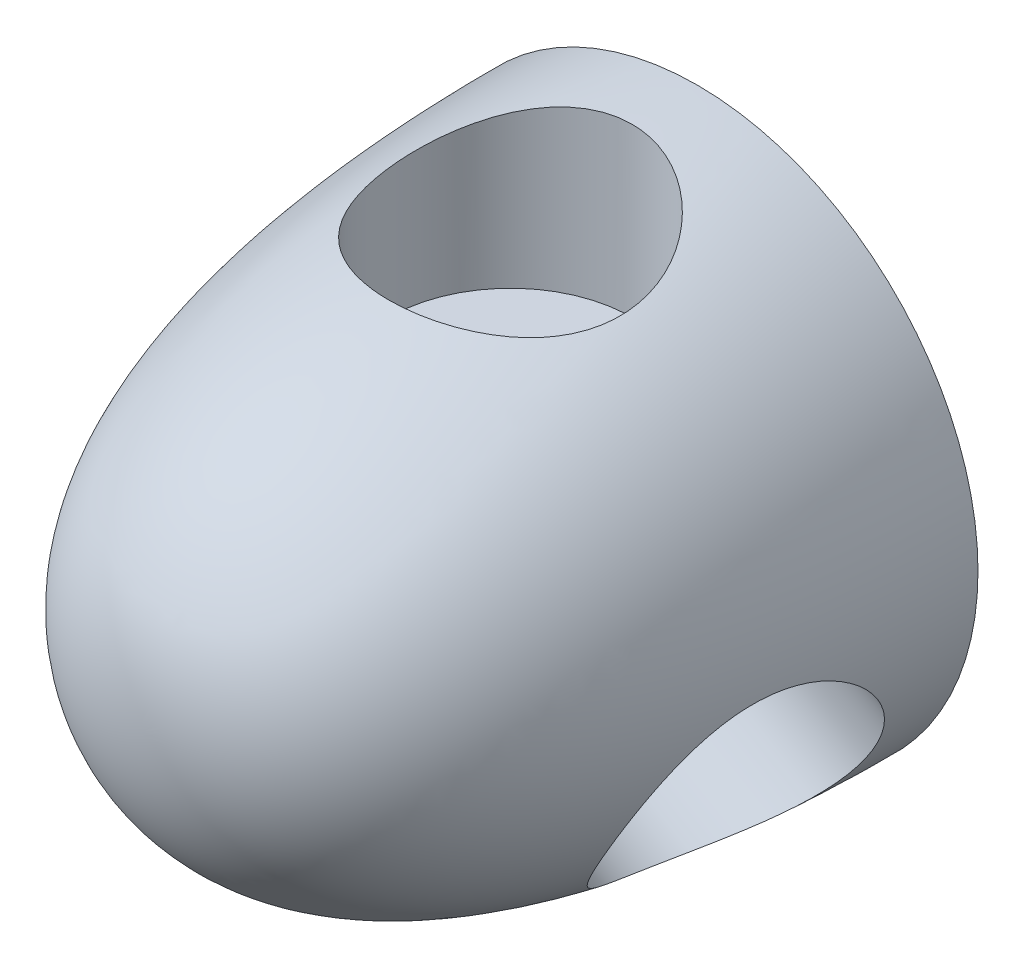
from build123d import *

# Parameters (mm, degrees)
SKETCH2_R          = 4.826
CUT_EXTRUDE1_DEPTH = 12.7
SKETCH4_R          = 8.255
CUT_EXTRUDE3_DEPTH = 16.256
CIRPATTERN1_COUNT  = 3


with BuildPart() as part:
    # Sketch1 → Revolve1 (revolve)
    with BuildSketch(Plane(origin=(0, 0, 0), x_dir=(0, 0, -1), z_dir=(1, 0, 0))):
        with BuildLine():
            Line((0, 0), (38.1, 0))
            Line((38.1, 0), (38.1, 19.05))
            add(Edge.make_bspline(
                [(0, 0), (0, 16.933744176), (23.900968343, 19.05), (38.1, 19.05)],
                knots=[0, 0, 0, 0, 1, 1, 1, 1], degree=3))
        make_face()
    revolve(axis=Axis((0, 0, 0), (0, 0, -1)))

    # Sketch2 → Cut-Extrude1 (cut)
    with BuildSketch(Plane(origin=(0, 0, -38.1), x_dir=(-1, 0, 0), z_dir=(0, 0, -1))):
        Circle(SKETCH2_R)
    extrude(amount=-CUT_EXTRUDE1_DEPTH, mode=Mode.SUBTRACT)

    # Sketch4 → Cut-Extrude3 (cut)
    with BuildSketch(Plane(origin=(0, 7.62, 0), x_dir=(1, 0, 0), z_dir=(0, 1, 0))):
        with Locations((0, 25.4)):
            Circle(SKETCH4_R)
    cut_extrude3 = extrude(amount=CUT_EXTRUDE3_DEPTH, mode=Mode.SUBTRACT)

    # CirPattern1: Cut-Extrude3 ×3 about axis
    cirpattern1_axis = Axis((0, 0, 0), (0, 0, 1))
    for i in range(1, CIRPATTERN1_COUNT):
        add(cut_extrude3.rotate(cirpattern1_axis, i * 360 / CIRPATTERN1_COUNT), mode=Mode.SUBTRACT)


solid = part.part
